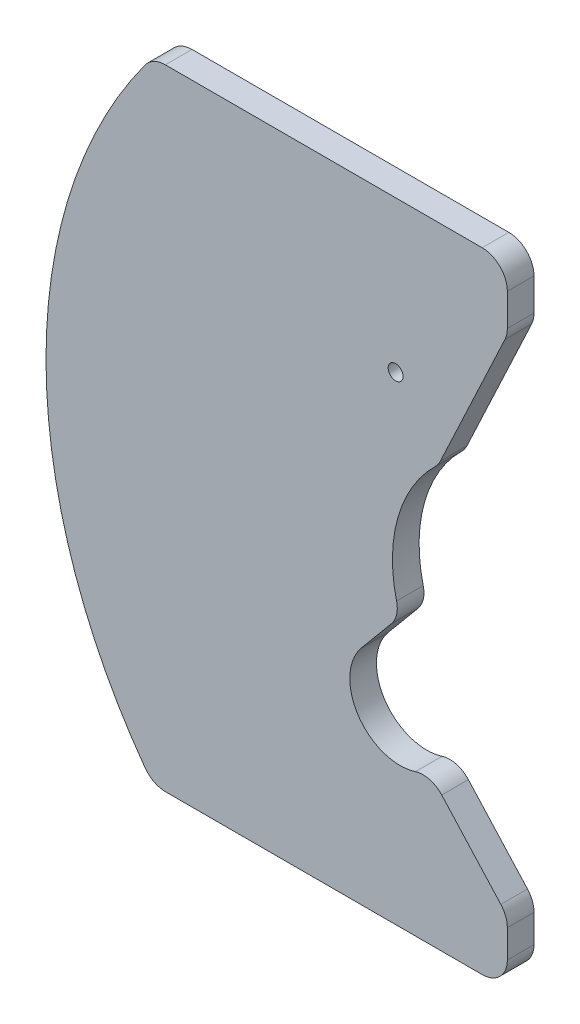
from build123d import *

# Parameters (mm, degrees)
SKETCH1_R           = 0.889
BOSS_EXTRUDE1_DEPTH = 3.175
FILLET1_R           = 3


with BuildPart() as part:
    # Sketch1 → Boss-Extrude1 (new body)
    with BuildSketch(Plane.XY):
        with BuildLine():
            Line((-57.387359122, 37.5), (-15.137359122, 37.5))
            Line((-15.137359122, 37.5), (-15.137359122, 30))
            Line((-15.137359122, 30), (-23.35327626, 12.490642695))
            ThreePointArc((-23.35327626, 12.490642695), (-28.301486723, 4.189647623), (-27.922607376, -5.466840166))
            Line((-27.922607376, -5.466840166), (-32.519153627, -10.979460849))
            ThreePointArc((-32.519153627, -10.979460849), (-32.321991252, -18.88915371), (-24.454232056, -19.726100177))
            Line((-24.454232056, -19.726100177), (-15.137359122, -30))
            Line((-15.137359122, -30), (-15.137359122, -37.5))
            Line((-15.137359122, -37.5), (-57.35903611, -37.5))
            ThreePointArc((-57.35903611, -37.5), (-70.10416265, -0.004807724), (-57.387359122, 37.5))
        make_face()
        with Locations((-28.448323012, 19.5)):
            Circle(SKETCH1_R, mode=Mode.SUBTRACT)
    extrude(amount=BOSS_EXTRUDE1_DEPTH)

    # Fillet1
    fillet1_edges = [part.edges().sort_by_distance(p)[0] for p in [
        (-24.454232056, -19.726100177, 1.5875),
        (-15.137359122, -30, 1.5875),
        (-15.137359122, -37.5, 1.5875),
        (-57.35903611, -37.5, 1.5875),
        (-57.387359122, 37.5, 1.5875),
        (-15.137359122, 37.5, 1.5875),
        (-15.137359122, 30, 1.5875),
        (-23.35327626, 12.490642695, 1.5875),
        (-27.922607376, -5.466840166, 1.5875),
    ]]
    fillet(fillet1_edges, radius=FILLET1_R)


solid = part.part
